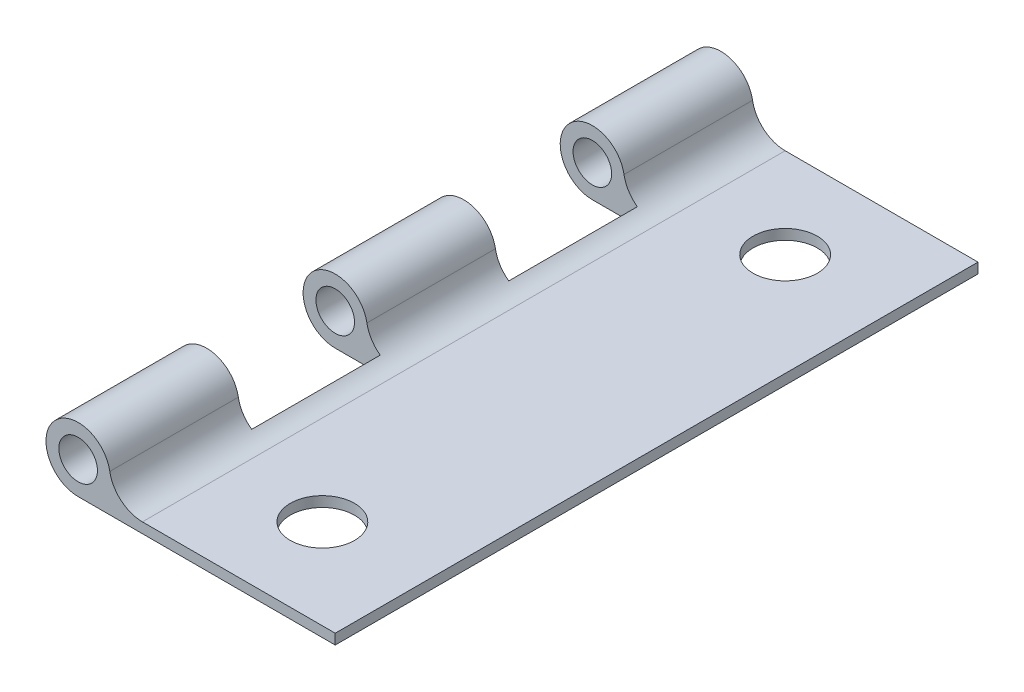
from build123d import *

# Parameters (mm, degrees)
ESBO_O1_R                = 1.5
RESSALTO_EXTRUS_O1_DEPTH = 50
ESBO_O2_R                = 2.5
ESBO_O2_W                = 6
ESBO_O2_H                = 10
CORTE_EXTRUS_O1_DEPTH    = 6


with BuildPart() as part:
    # Esboço1 → Ressalto-extrusão1 (new body)
    with BuildSketch(Plane.XY):
        with BuildLine():
            Line((0, 0), (-20, 0))
            ThreePointArc((-20, 0), (-22.499911314, 2.521057642), (-19.95788621, 4.999645261))
            ThreePointArc((-19.95788621, 4.999645261), (-18.375952887, 4.400650146), (-17.537523452, 2.9315197))
            ThreePointArc((-17.537523452, 2.9315197), (-16.656985327, 1.403588896), (-15, 0.8))
            Line((-15, 0.8), (0, 0.8))
            Line((0, 0.8), (0, 0))
        make_face()
        with Locations((-20, 2.5)):
            Circle(ESBO_O1_R, mode=Mode.SUBTRACT)
    extrude(amount=RESSALTO_EXTRUS_O1_DEPTH)

    # Esboço2 → Corte-extrusão1 (cut, through all)
    with BuildSketch(Plane.XZ):
        with Locations((-8, 43)):
            Circle(ESBO_O2_R)
        with Locations((-8, 7)):
            Circle(ESBO_O2_R)
        with Locations((-19.5, 15)):
            Rectangle(ESBO_O2_W, ESBO_O2_H)
        with Locations((-19.5, 35)):
            Rectangle(ESBO_O2_W, ESBO_O2_H)
    extrude(amount=-CORTE_EXTRUS_O1_DEPTH, mode=Mode.SUBTRACT)


solid = part.part
